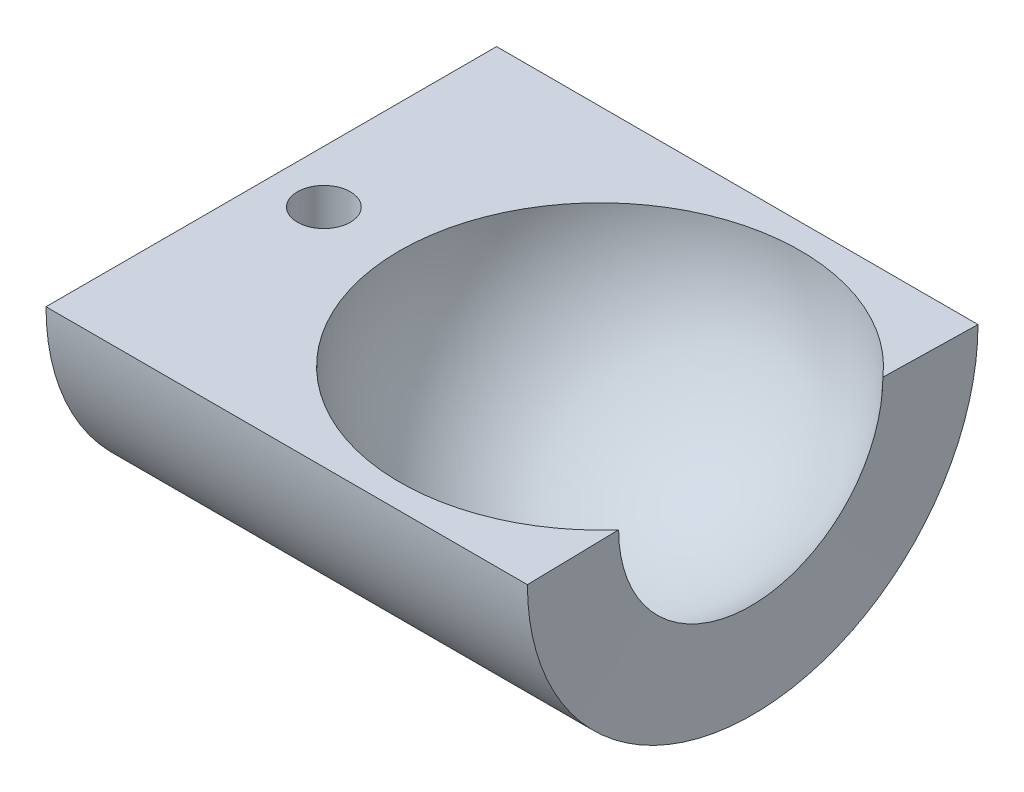
from build123d import *

# Parameters (mm, degrees)
CORTAR_EXTRUIR3_DEPTH = 45
CROQUIS6_R            = 1.65
CORTAR_EXTRUIR4_DEPTH = 20


with BuildPart() as part:
    # Croquis1 → Revolución3 (revolve)
    with BuildSketch(Plane(origin=(0, 0, 0), x_dir=(1, 0, 0), z_dir=(0, 1, 0))):
        with BuildLine():
            Line((-12.5, 0), (-20.5, 0))
            Line((-20.5, 0), (-20.5, 14.049477092))
            Line((-20.5, 14.049477092), (9.52106407, 14.049477092))
            Line((9.52106407, 14.049477092), (9.399951047, 8.239594669))
            ThreePointArc((9.399951047, 8.239594669), (-4.40173897, 11.699345881), (-12.5, 0))
        make_face()
    revolve(axis=Axis((-12.5, 0, 0), (-1, 0, 0)))

    # Croquis5 → Cortar-Extruir3 (cut)
    with BuildSketch(Plane.ZY.offset(20.5)):
        Polygon((0, 0), (-16.832618664, 0), (-16.832618664, 15.474654251), (15.925083383, 15.474654251), (15.925083383, 0), align=None)
    extrude(amount=-CORTAR_EXTRUIR3_DEPTH, mode=Mode.SUBTRACT)

    # Croquis6 → Cortar-Extruir4 (cut)
    with BuildSketch(Plane(origin=(0, 0, 0), x_dir=(1, 0, 0), z_dir=(0, 1, 0))):
        with Locations((-17.221724739, 0)):
            Circle(CROQUIS6_R)
    extrude(amount=-CORTAR_EXTRUIR4_DEPTH, mode=Mode.SUBTRACT)


solid = part.part
